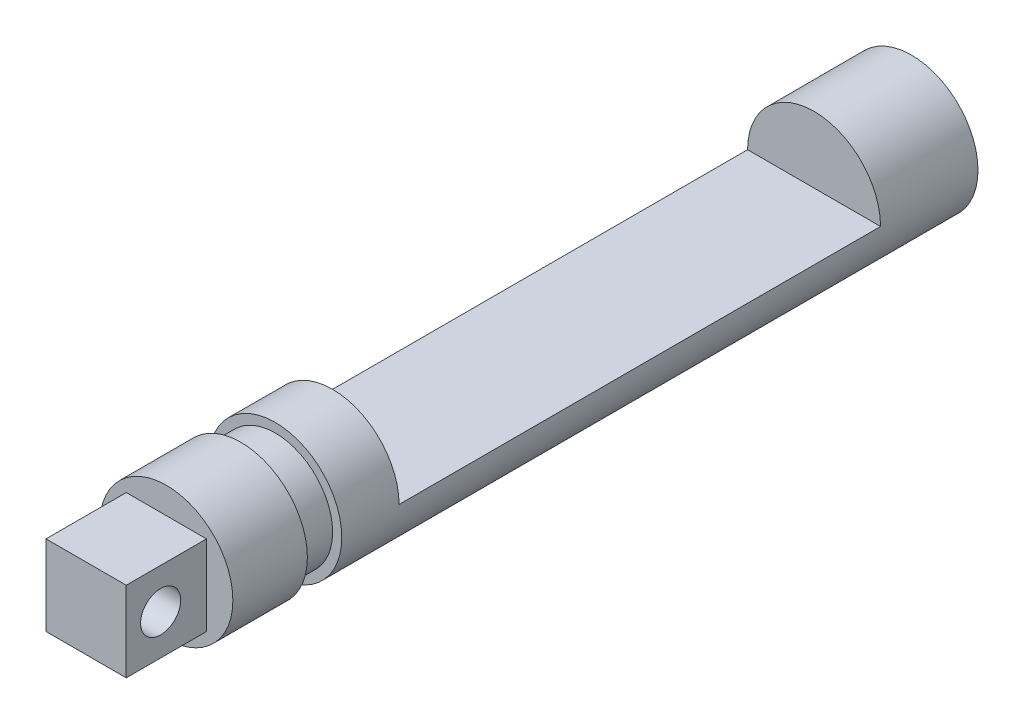
from build123d import *

# Parameters (mm, degrees)
CROQUIS1_R                   = 5.8
SALIENTE_EXTRUIR1_DEPTH      = 32.5
CORTAR_EXTRUIR1_DEPTH        = 24
CORTAR_EXTRUIR_L_MINA1_START = -6.5
CROQUIS3_R                   = 5.8
CROQUIS3_R_2                 = 5
CORTAR_EXTRUIR_L_MINA1_DEPTH = 3
CROQUIS4_W                   = 7
CROQUIS4_H                   = 7
SALIENTE_EXTRUIR2_DEPTH      = 7
CROQUIS6_R                   = 1.75
CORTAR_EXTRUIR3_DEPTH        = 41.992438327
CORTAR_EXTRUIR4_START        = 18
CORTAR_EXTRUIR4_DEPTH        = 18


with BuildPart() as part:
    # Croquis1 → Saliente-Extruir1 (new, symmetric)
    with BuildSketch(Plane.XY):
        Circle(CROQUIS1_R)
    extrude(amount=SALIENTE_EXTRUIR1_DEPTH, both=True)

    # Croquis2 → Cortar-Extruir1 (cut)
    with BuildSketch(Plane.XY):
        with BuildLine():
            Line((-5.8, 0), (5.8, 0))
            ThreePointArc((5.8, 0), (0, 5.8), (-5.8, 0))
        make_face()
    extrude(amount=-CORTAR_EXTRUIR1_DEPTH, mode=Mode.SUBTRACT)

    # Croquis3 → Cortar-Extruir-Lámina1 (cut)
    with BuildSketch(Plane.XY.offset(32.5).offset(CORTAR_EXTRUIR_L_MINA1_START)):
        Circle(CROQUIS3_R)
        Circle(CROQUIS3_R_2, mode=Mode.SUBTRACT)
    extrude(amount=-CORTAR_EXTRUIR_L_MINA1_DEPTH, mode=Mode.SUBTRACT)

    # Croquis4 → Saliente-Extruir2 (add)
    with BuildSketch(Plane.XY.offset(32.5)):
        Rectangle(CROQUIS4_W, CROQUIS4_H)
    extrude(amount=SALIENTE_EXTRUIR2_DEPTH)

    # Croquis6 → Cortar-Extruir3 (cut, through all)
    with BuildSketch(Plane.ZY.offset(3.5)):
        with Locations((36.5, 0)):
            Circle(CROQUIS6_R)
    extrude(amount=-CORTAR_EXTRUIR3_DEPTH, mode=Mode.SUBTRACT)

    # Croquis2_2 → Cortar-Extruir4 (cut)
    with BuildSketch(Plane.XY.offset(CORTAR_EXTRUIR4_START)):
        with BuildLine():
            Line((-5.8, 0), (5.8, 0))
            ThreePointArc((5.8, 0), (0, 5.8), (-5.8, 0))
        make_face()
    extrude(amount=-CORTAR_EXTRUIR4_DEPTH, mode=Mode.SUBTRACT)


solid = part.part
